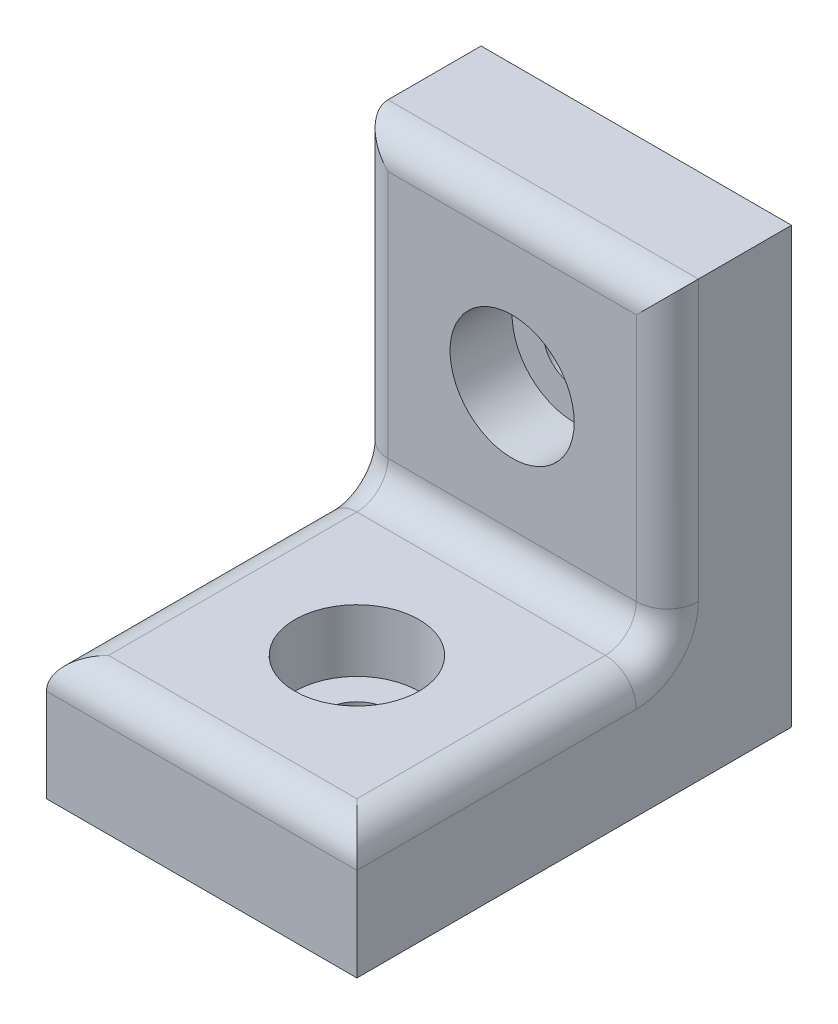
from build123d import *

# Parameters (mm, degrees)
ESQUISSE1_W             = 10
ESQUISSE1_H             = 14
BOSS_EXTRU_1_DEPTH      = 4
ESQUISSE2_W             = 10
ESQUISSE2_H             = 4
BOSS_EXTRU_2_DEPTH      = 10
ESQUISSE3_R             = 1
ENL_V_MAT_EXTRU_1_DEPTH = 5
CONG_1_R                = 1
ESQUISSE4_R             = 1
ENL_V_MAT_EXTRU_2_DEPTH = 5
ESQUISSE5_R             = 2
ENL_V_MAT_EXTRU_3_DEPTH = 2
ESQUISSE6_R             = 2
ENL_V_MAT_EXTRU_4_DEPTH = 2


with BuildPart() as part:
    # Esquisse1 → Boss.-Extru.1 (new body)
    with BuildSketch(Plane.XY):
        with Locations((0, 7)):
            Rectangle(ESQUISSE1_W, ESQUISSE1_H)
    extrude(amount=BOSS_EXTRU_1_DEPTH)

    # Esquisse2 → Boss.-Extru.2 (add)
    with BuildSketch(Plane.XY.offset(4)):
        with Locations((0, 2)):
            Rectangle(ESQUISSE2_W, ESQUISSE2_H)
    extrude(amount=BOSS_EXTRU_2_DEPTH)

    # Esquisse3 → Enlèv. mat.-Extru.1 (cut, through all)
    with BuildSketch(Plane.XY.offset(4)):
        with Locations((0, 9)):
            Circle(ESQUISSE3_R)
    extrude(amount=-ENL_V_MAT_EXTRU_1_DEPTH, mode=Mode.SUBTRACT)

    # Congé1
    cong_1_edges = [part.edges().sort_by_distance(p)[0] for p in [
        (5, 9, 4),
        (-5, 4, 9),
        (0, 4, 4),
        (5, 4, 9),
        (0, 14, 4),
        (0, 4, 14),
        (-5, 9, 4),
    ]]
    fillet(cong_1_edges, radius=CONG_1_R)

    # Esquisse4 → Enlèv. mat.-Extru.2 (cut, through all)
    with BuildSketch(Plane(origin=(0, 4, 0), x_dir=(1, 0, 0), z_dir=(0, 1, 0))):
        with Locations(Location((0, -9, 0), (0, 0, 270))):  # turned: the seam where the file's is
            Circle(ESQUISSE4_R)
    extrude(amount=-ENL_V_MAT_EXTRU_2_DEPTH, mode=Mode.SUBTRACT)

    # Esquisse5 → Enlèv. mat.-Extru.3 (cut)
    with BuildSketch(Plane.XY.offset(4)):
        with Locations((0, 9)):
            Circle(ESQUISSE5_R)
    extrude(amount=-ENL_V_MAT_EXTRU_3_DEPTH, mode=Mode.SUBTRACT)

    # Esquisse6 → Enlèv. mat.-Extru.4 (cut)
    with BuildSketch(Plane(origin=(0, 4, 0), x_dir=(1, 0, 0), z_dir=(0, 1, 0))):
        with Locations(Location((0, -9, 0), (0, 0, 270))):  # turned: the seam where the file's is
            Circle(ESQUISSE6_R)
    extrude(amount=-ENL_V_MAT_EXTRU_4_DEPTH, mode=Mode.SUBTRACT)


solid = part.part
